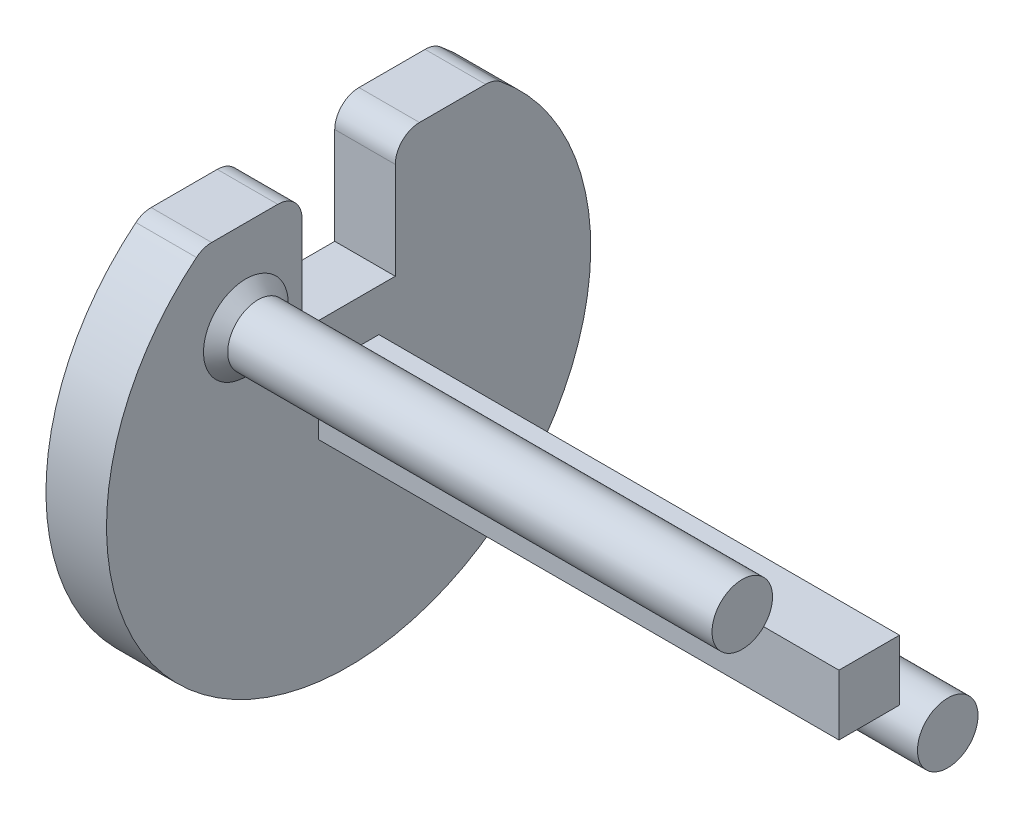
from build123d import *

# Parameters (mm, degrees)
SKETCH2_R           = 20
BOSS_EXTRUDE2_DEPTH = 5
SKETCH3_W           = 5
SKETCH3_H           = 5
BOSS_EXTRUDE3_DEPTH = 43
SKETCH4_R           = 2.5
BOSS_EXTRUDE4_DEPTH = 41
SKETCH5_W           = 7.704684196
SKETCH5_H           = 10
CUT_EXTRUDE1_DEPTH  = 6
FILLET1_R           = 2
CHAMFER1_SIZE       = 1


with BuildPart() as part:
    # Sketch2 → Boss-Extrude2 (new body)
    with BuildSketch(Plane(origin=(0, 0, 0), x_dir=(0, 0, -1), z_dir=(1, 0, 0))):
        Circle(SKETCH2_R)
    extrude(amount=BOSS_EXTRUDE2_DEPTH)

    # Sketch3 → Boss-Extrude3 (add)
    with BuildSketch(Plane(origin=(5, 0, 0), x_dir=(0, 0, -1), z_dir=(1, 0, 0))):
        Rectangle(SKETCH3_W, SKETCH3_H)
    extrude(amount=BOSS_EXTRUDE3_DEPTH)

    # Sketch4 → Boss-Extrude4 (add)
    with BuildSketch(Plane(origin=(5, 0, 0), x_dir=(0, 0, -1), z_dir=(1, 0, 0))):
        with Locations((-8.485281374, 8.485281374)):
            Circle(SKETCH4_R)
        with Locations((8.485281374, -8.485281374)):
            Circle(SKETCH4_R)
    extrude(amount=BOSS_EXTRUDE4_DEPTH)

    # Sketch5 → Cut-Extrude1 (cut, through all)
    with BuildSketch(Plane(origin=(5, 0, 0), x_dir=(0, 0, -1), z_dir=(1, 0, 0))):
        with BuildLine():
            Line((-12, 16), (-3.852342098, 16))
            Line((-3.852342098, 16), (-3.852342098, 19.625479876))
            ThreePointArc((-3.852342098, 19.625479876), (-8.130818752, 18.272651324), (-12, 16))
        make_face()
        with BuildLine():
            Line((-3.852342098, 19.625479876), (-3.852342098, 16))
            Line((-3.852342098, 16), (3.852342098, 16))
            Line((3.852342098, 16), (3.852342098, 19.625479876))
            ThreePointArc((3.852342098, 19.625479876), (1.935252254, 19.906149771), (2.3e-08, 20))
            ThreePointArc((2.3e-08, 20), (-1.935252231, 19.906149773), (-3.852342098, 19.625479876))
        make_face()
        with BuildLine():
            Line((3.852342098, 19.625479876), (3.852342098, 16))
            Line((3.852342098, 16), (12, 16))
            ThreePointArc((12, 16), (8.130818752, 18.272651324), (3.852342098, 19.625479876))
        make_face()
        with Locations((0, 11)):
            Rectangle(SKETCH5_W, SKETCH5_H)
    extrude(amount=-CUT_EXTRUDE1_DEPTH, mode=Mode.SUBTRACT)

    # Fillet1
    fillet1_edges = [part.edges().sort_by_distance(p)[0] for p in [
        (2.5, 16, 12),
        (2.5, 16, -12),
        (2.5, 16, -3.852342098),
        (2.5, 16, 3.852342098),
    ]]
    fillet(fillet1_edges, radius=FILLET1_R)

    # Chamfer1
    chamfer1_edges = [part.edges().sort_by_distance(p)[0] for p in [
        (5, 8.485281374, 10.985281374),
        (5, -8.485281374, -5.985281374),
    ]]
    chamfer(chamfer1_edges, length=CHAMFER1_SIZE)


solid = part.part
